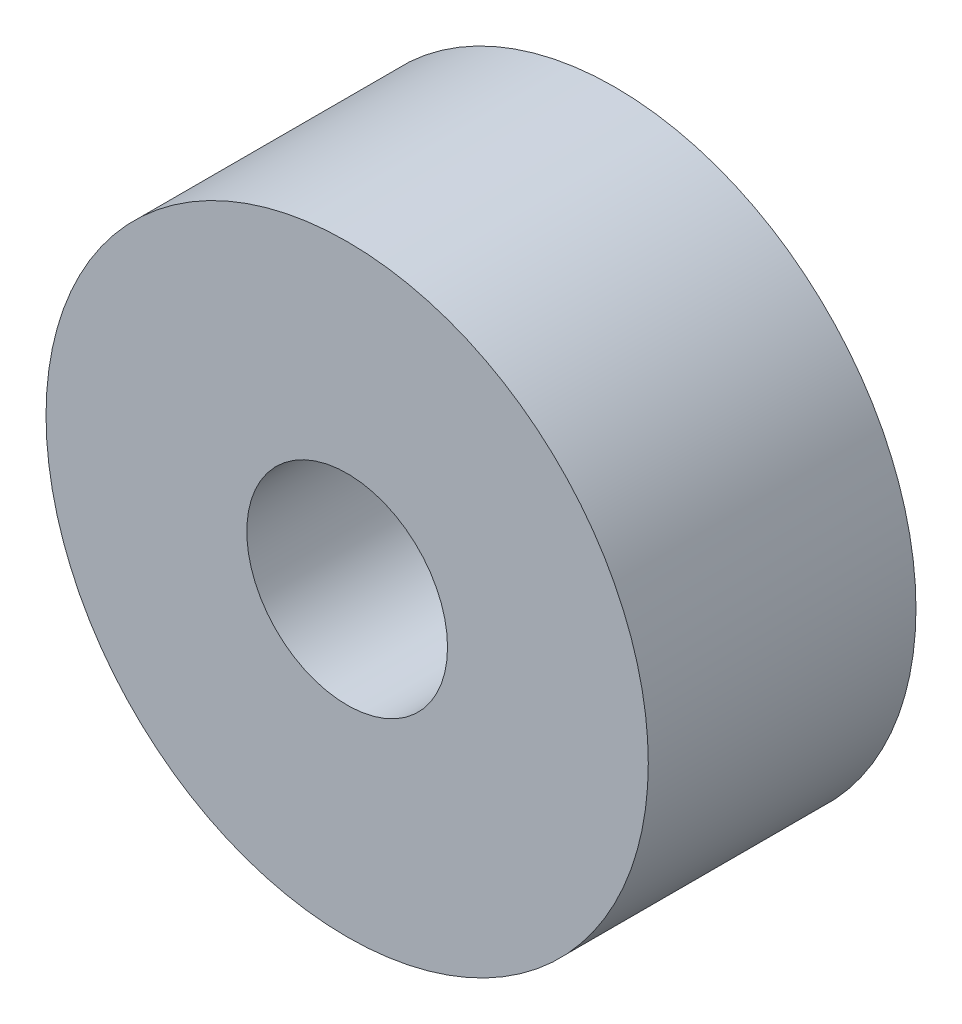
from build123d import *

# Parameters (mm, degrees)
ESBO_O1_R                = 4.5
ESBO_O1_R_2              = 1.5
RESSALTO_EXTRUS_O1_DEPTH = 4


with BuildPart() as part:
    # Esboço1 → Ressalto-extrusão1 (new body)
    with BuildSketch(Plane.XY):
        Circle(ESBO_O1_R)
        Circle(ESBO_O1_R_2, mode=Mode.SUBTRACT)
    extrude(amount=RESSALTO_EXTRUS_O1_DEPTH)


solid = part.part
